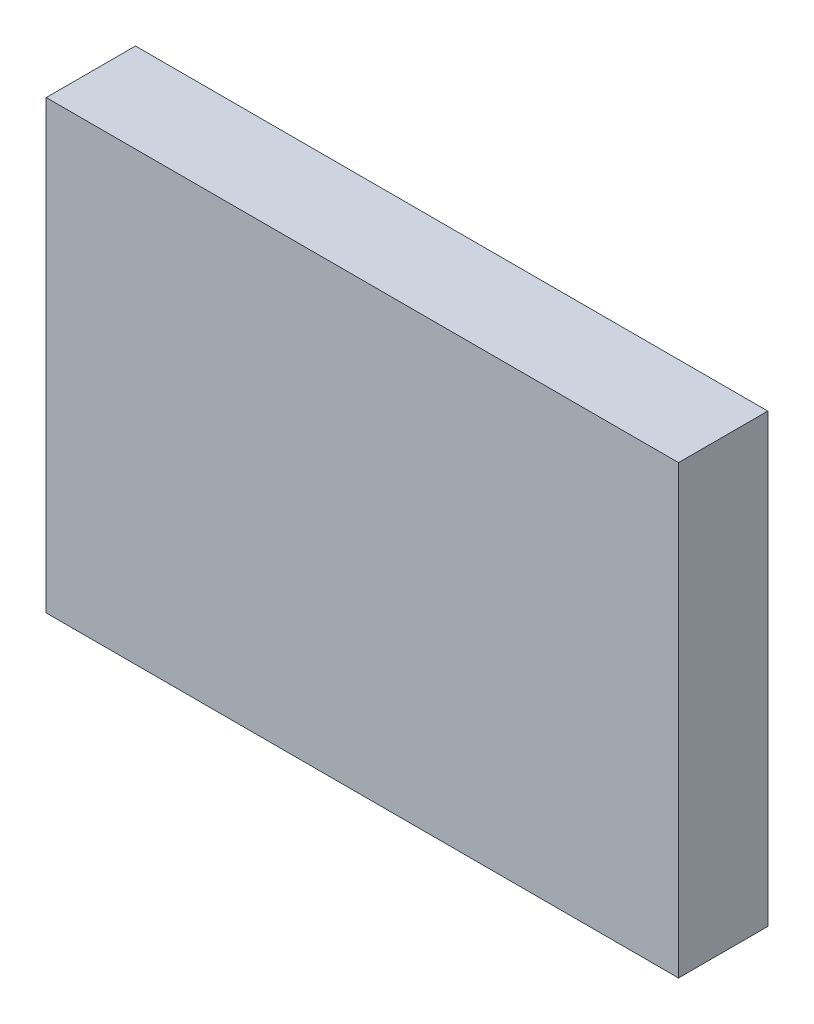
from build123d import *

# Parameters (mm, degrees)
ESQUISSE1_W        = 85
ESQUISSE1_H        = 60
BOSS_EXTRU_1_DEPTH = 12


with BuildPart() as part:
    # Esquisse1 → Boss.-Extru.1 (new body)
    with BuildSketch(Plane.XY):
        with Locations((42.5, 30)):
            Rectangle(ESQUISSE1_W, ESQUISSE1_H)
    extrude(amount=BOSS_EXTRU_1_DEPTH)


solid = part.part
